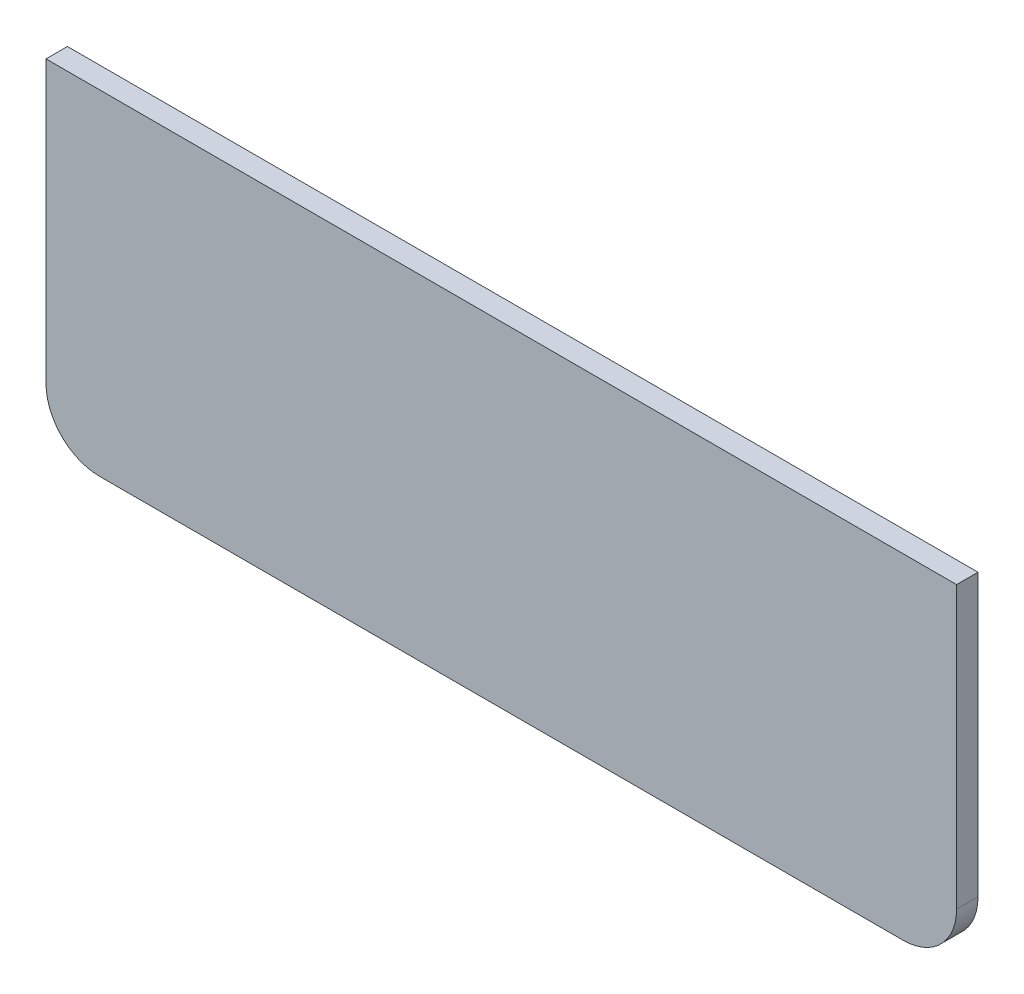
from build123d import *

# Parameters (mm, degrees)
EXTRUDE_1_DEPTH = 1.6


with BuildPart() as part:
    # Эскиз1 → Бобышка-Вытянуть1 (new body)
    with BuildSketch(Plane.XY):
        with BuildLine():
            Line((-30, -12.5), (30, -12.5))
            ThreePointArc((30, -12.5), (32.828427125, -11.328427125), (34, -8.5))
            Line((34, -8.5), (34, 12.5))
            Line((34, 12.5), (-34, 12.5))
            Line((-34, 12.5), (-34, -8.5))
            ThreePointArc((-34, -8.5), (-32.828427125, -11.328427125), (-30, -12.5))
        make_face()
    extrude(amount=EXTRUDE_1_DEPTH)


solid = part.part
